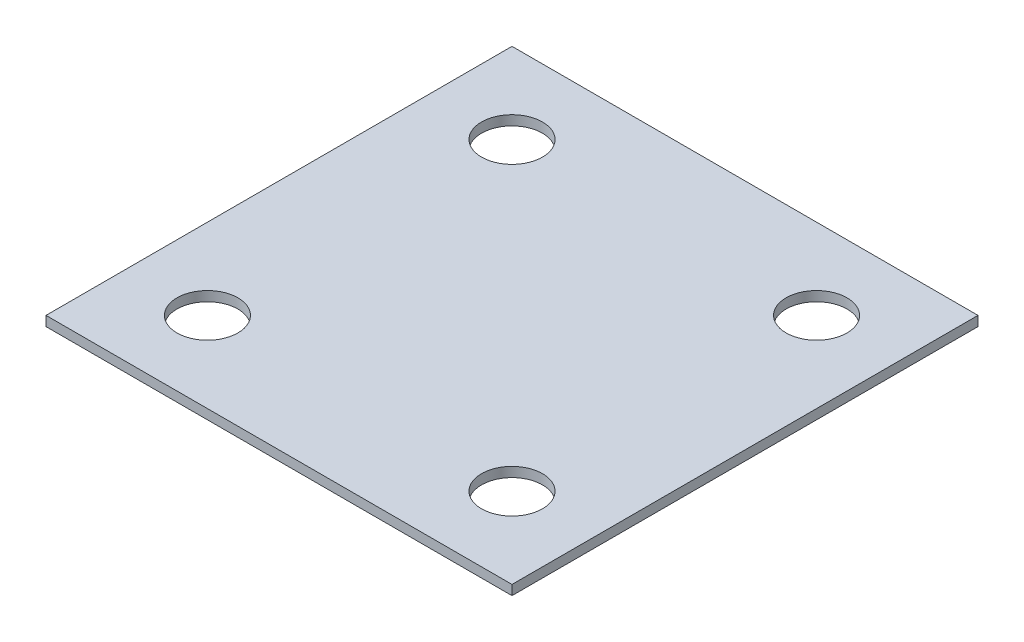
from build123d import *

# Parameters (mm, degrees)
SKETCH1_W           = 765
SKETCH1_H           = 765
BOSS_EXTRUDE1_DEPTH = 16
CUT_EXTRUDE2_REACH  = 18
SKETCH5_R           = 50


with BuildPart() as part:
    # Sketch1 → Boss-Extrude1 (new body)
    with BuildSketch(Plane(origin=(0, 0, 0), x_dir=(1, 0, 0), z_dir=(0, 1, 0))):
        Rectangle(SKETCH1_W, SKETCH1_H)
    extrude(amount=BOSS_EXTRUDE1_DEPTH)

    # Sketch5 → Cut-Extrude2 (cut, up to next)
    with BuildSketch(Plane(origin=(0, 16, 0), x_dir=(1, 0, 0), z_dir=(0, 1, 0)), mode=Mode.PRIVATE) as cut_extrude2_sk1:
        with Locations((-250, 250)):
            Circle(SKETCH5_R)
    cut_extrude2_tool1 = extrude(cut_extrude2_sk1.sketch, amount=-CUT_EXTRUDE2_REACH, mode=Mode.PRIVATE) & part.part
    add(cut_extrude2_tool1.solids().sort_by_distance((-250, 16, -250))[0], mode=Mode.SUBTRACT)
    # Sketch5 → Cut-Extrude2 (cut, up to next)
    with BuildSketch(Plane(origin=(0, 16, 0), x_dir=(1, 0, 0), z_dir=(0, 1, 0)), mode=Mode.PRIVATE) as cut_extrude2_sk2:
        with Locations((250, 250)):
            Circle(SKETCH5_R)
    cut_extrude2_tool2 = extrude(cut_extrude2_sk2.sketch, amount=-CUT_EXTRUDE2_REACH, mode=Mode.PRIVATE) & part.part
    add(cut_extrude2_tool2.solids().sort_by_distance((250, 16, -250))[0], mode=Mode.SUBTRACT)
    # Sketch5 → Cut-Extrude2 (cut, up to next)
    with BuildSketch(Plane(origin=(0, 16, 0), x_dir=(1, 0, 0), z_dir=(0, 1, 0)), mode=Mode.PRIVATE) as cut_extrude2_sk3:
        with Locations((250, -250)):
            Circle(SKETCH5_R)
    cut_extrude2_tool3 = extrude(cut_extrude2_sk3.sketch, amount=-CUT_EXTRUDE2_REACH, mode=Mode.PRIVATE) & part.part
    add(cut_extrude2_tool3.solids().sort_by_distance((250, 16, 250))[0], mode=Mode.SUBTRACT)
    # Sketch5 → Cut-Extrude2 (cut, up to next)
    with BuildSketch(Plane(origin=(0, 16, 0), x_dir=(1, 0, 0), z_dir=(0, 1, 0)), mode=Mode.PRIVATE) as cut_extrude2_sk4:
        with Locations((-250, -250)):
            Circle(SKETCH5_R)
    cut_extrude2_tool4 = extrude(cut_extrude2_sk4.sketch, amount=-CUT_EXTRUDE2_REACH, mode=Mode.PRIVATE) & part.part
    add(cut_extrude2_tool4.solids().sort_by_distance((-250, 16, 250))[0], mode=Mode.SUBTRACT)


solid = part.part
